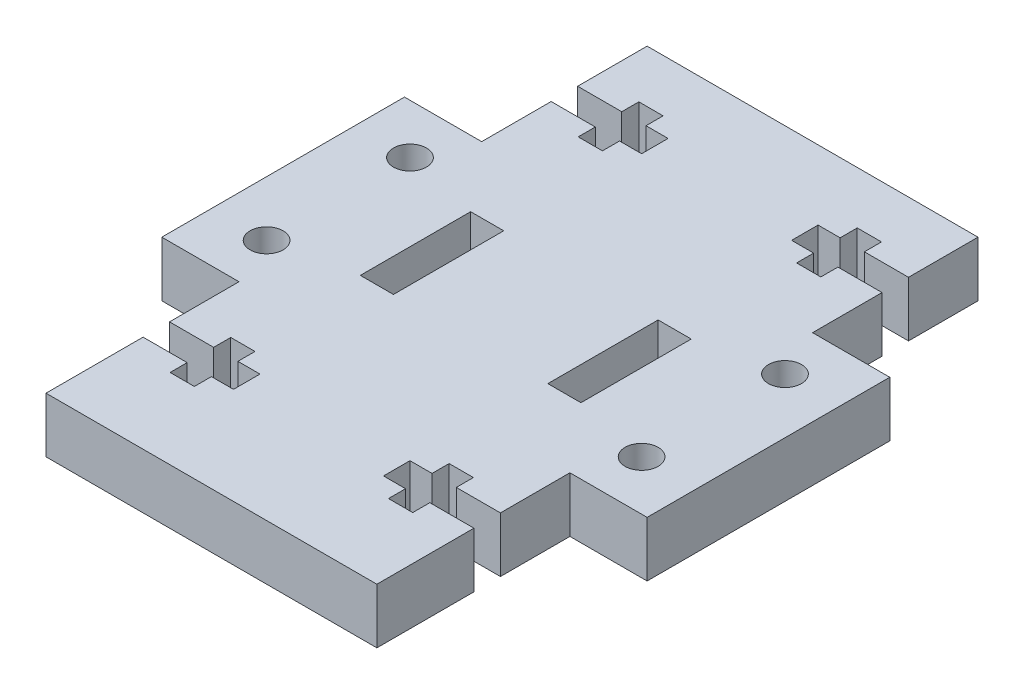
from build123d import *

# Parameters (mm, degrees)
SKETCH2_R           = 1.5
SKETCH2_W           = 3
SKETCH2_H           = 10
BOSS_EXTRUDE2_DEPTH = 5
CUT_EXTRUDE1_DEPTH  = 6


with BuildPart() as part:
    # Sketch2 → Boss-Extrude2 (new body)
    with BuildSketch(Plane(origin=(0, 0, 0), x_dir=(1, 0, 0), z_dir=(0, 1, 0))):
        Polygon((9.607122403, -57.726350335), (39.607122403, -57.726350335), (39.607122403, -40.226350335), (46.607122403, -40.226350335), (46.607122403, -18.226350335), (39.607122403, -18.226350335), (39.607122403, -3.226350335), (9.607122403, -3.226350335), (9.607122403, -18.226350335), (2.607122403, -18.226350335), (2.607122403, -40.226350335), (9.607122403, -40.226350335), align=None)
        with Locations((41.607122403, -22.726350335)):
            Circle(SKETCH2_R, mode=Mode.SUBTRACT)
        with Locations((41.607122403, -35.726350335)):
            Circle(SKETCH2_R, mode=Mode.SUBTRACT)
        with Locations((7.607122403, -35.726350335)):
            Circle(SKETCH2_R, mode=Mode.SUBTRACT)
        with Locations((7.607122403, -22.726350335)):
            Circle(SKETCH2_R, mode=Mode.SUBTRACT)
        with Locations((33.107122403, -29.226350335)):
            Rectangle(SKETCH2_W, SKETCH2_H, mode=Mode.SUBTRACT)
        with Locations((16.107122403, -29.226350335)):
            Rectangle(SKETCH2_W, SKETCH2_H, mode=Mode.SUBTRACT)
    extrude(amount=BOSS_EXTRUDE2_DEPTH)

    # Sketch3 → Cut-Extrude1 (cut, through all)
    with BuildSketch(Plane(origin=(0, 5, 0), x_dir=(-1, 0, 0), z_dir=(0, 1, 0))):
        Polygon((-39.607122403, 46.526350335), (-35.607122403, 46.526350335), (-35.607122403, 44.976350335), (-33.407122403, 44.976350335), (-33.407122403, 46.526350335), (-31.407122403, 46.526350335), (-31.407122403, 48.926350335), (-33.407122403, 48.926350335), (-33.407122403, 50.476350335), (-35.607122403, 50.476350335), (-35.607122403, 48.926350335), (-39.607122403, 48.926350335), align=None)
        Polygon((-39.607122403, 9.526350335), (-35.607122403, 9.526350335), (-35.607122403, 7.976350335), (-33.407122403, 7.976350335), (-33.407122403, 9.526350335), (-31.407122403, 9.526350335), (-31.407122403, 11.926350335), (-33.407122403, 11.926350335), (-33.407122403, 13.476350335), (-35.607122403, 13.476350335), (-35.607122403, 11.926350335), (-39.607122403, 11.926350335), align=None)
        Polygon((-13.607122403, 50.476350335), (-15.807122403, 50.476350335), (-15.807122403, 48.926350335), (-17.807122403, 48.926350335), (-17.807122403, 46.526350335), (-15.807122403, 46.526350335), (-15.807122403, 44.976350335), (-13.607122403, 44.976350335), (-13.607122403, 46.526350335), (-9.607122403, 46.526350335), (-9.607122403, 48.926350335), (-13.607122403, 48.926350335), align=None)
        Polygon((-9.607122403, 11.926350335), (-13.607122403, 11.926350335), (-13.607122403, 13.476350335), (-15.807122403, 13.476350335), (-15.807122403, 11.926350335), (-17.807122403, 11.926350335), (-17.807122403, 9.526350335), (-15.807122403, 9.526350335), (-15.807122403, 7.976350335), (-13.607122403, 7.976350335), (-13.607122403, 9.526350335), (-9.607122403, 9.526350335), align=None)
    extrude(amount=-CUT_EXTRUDE1_DEPTH, mode=Mode.SUBTRACT)


solid = part.part
